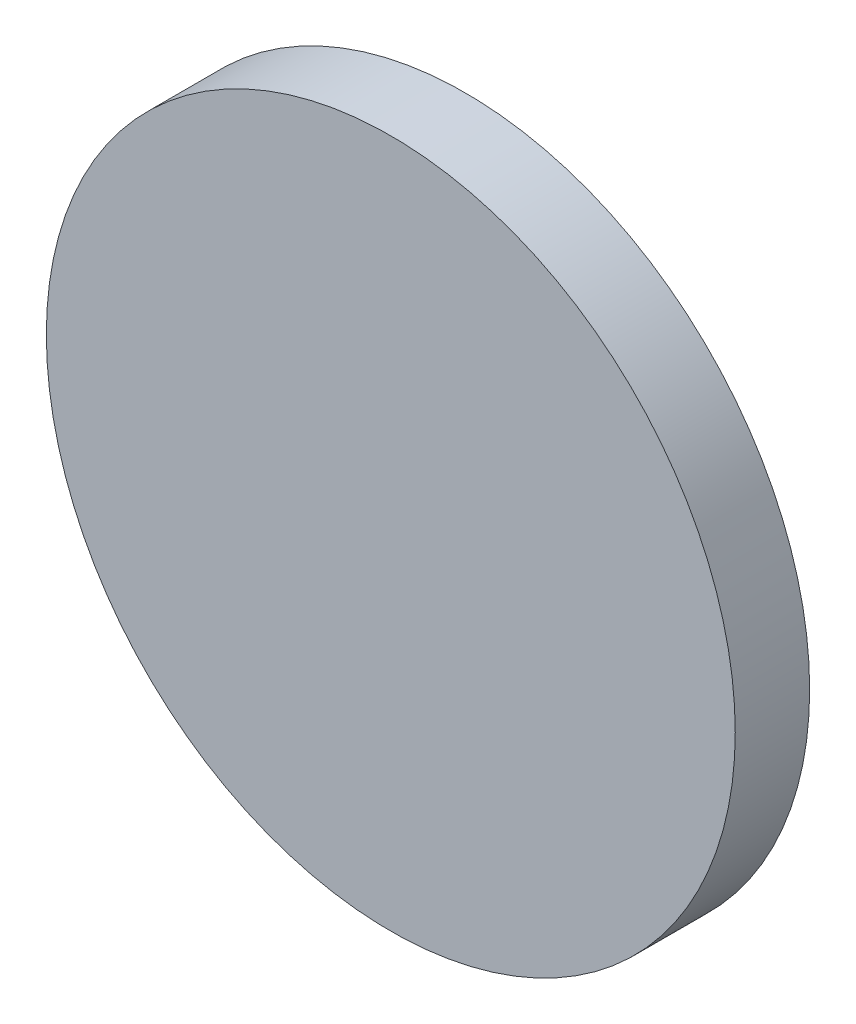
from build123d import *

# Parameters (mm, degrees)
SKETCH1_R           = 32.09925
BOSS_EXTRUDE1_DEPTH = 6.9342


with BuildPart() as part:
    # Sketch1 → Boss-Extrude1 (new body)
    with BuildSketch(Plane.XY):
        Circle(SKETCH1_R)
    extrude(amount=BOSS_EXTRUDE1_DEPTH)


solid = part.part
